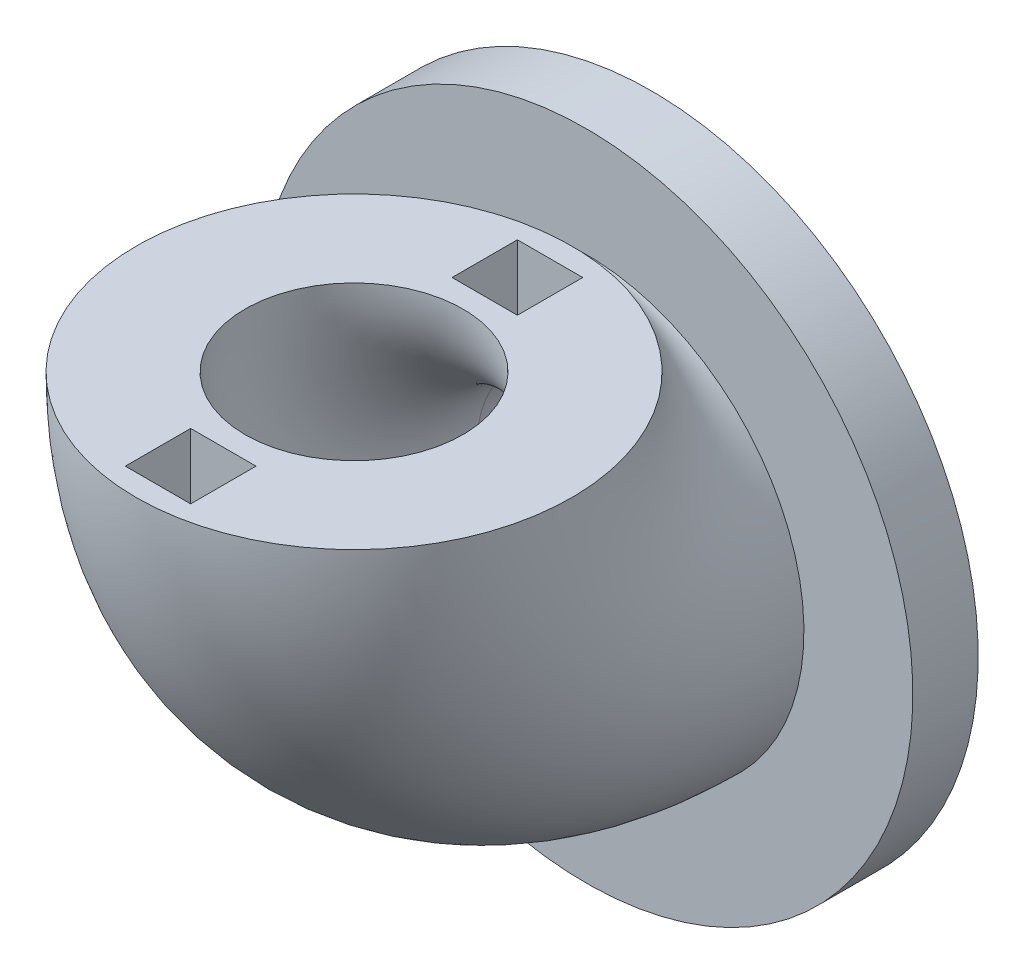
from build123d import *

# Parameters (mm, degrees)
SKETCH1_R           = 10
SKETCH1_R_2         = 5
SKETCH4_R           = 15
SKETCH4_R_2         = 5
BOSS_EXTRUDE1_DEPTH = 3
SKETCH5_W           = 3
SKETCH5_H           = 3
CUT_EXTRUDE1_DEPTH  = 3


with BuildPart() as part:
    # Sweep1: sweep along a path in Sketch3
    with BuildLine(Plane(origin=(0, 0, 0), x_dir=(0, 0, -1), z_dir=(1, 0, 0))) as sweep1_path:
        ThreePointArc((0, 0), (-7.533795299, 3.120600189), (-10.654395489, 10.654395489))
    # Sketch1 → Sweep1 (sweep)
    with BuildSketch(Plane.XY):
        Circle(SKETCH1_R)
        Circle(SKETCH1_R_2, mode=Mode.SUBTRACT)
    sweep(path=sweep1_path.line)

    # Sketch4 → Boss-Extrude1 (add)
    with BuildSketch(Plane(origin=(0, 0, 0), x_dir=(-1, 0, 0), z_dir=(0, 0, -1))):
        Circle(SKETCH4_R)
        Circle(SKETCH4_R_2, mode=Mode.SUBTRACT)
    extrude(amount=BOSS_EXTRUDE1_DEPTH)

    # Sketch5 → Cut-Extrude1 (cut)
    with BuildSketch(Plane(origin=(0, 10.654395489, 0), x_dir=(1, 0, 0), z_dir=(0, 1, 0))):
        with Locations((0, -3.154395489)):
            Rectangle(SKETCH5_W, SKETCH5_H)
        with Locations((0, -18.154395489)):
            Rectangle(SKETCH5_W, SKETCH5_H)
    extrude(amount=-CUT_EXTRUDE1_DEPTH, mode=Mode.SUBTRACT)


solid = part.part
